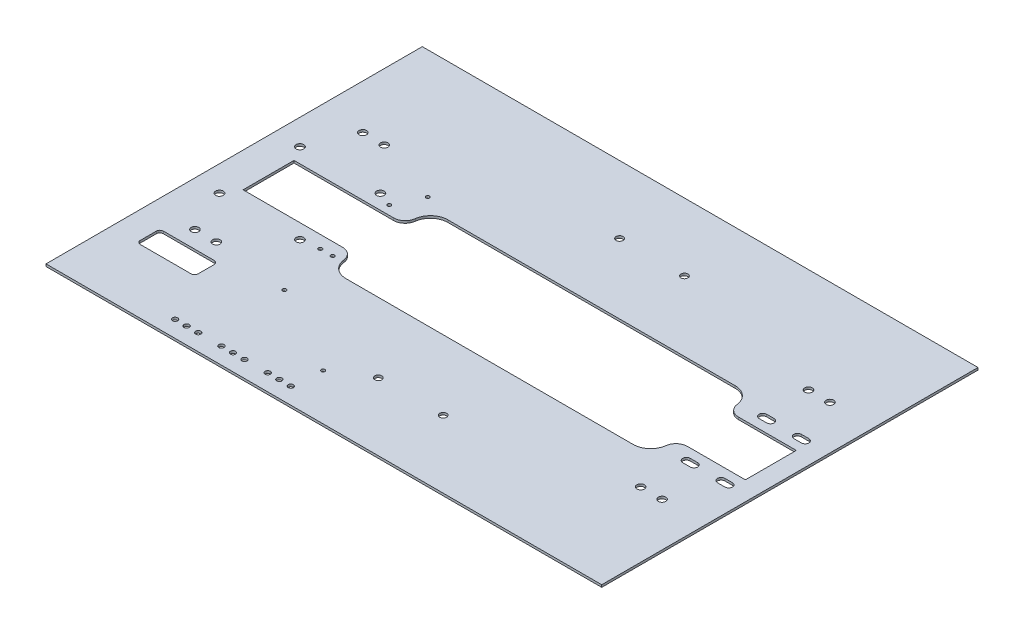
from build123d import *

# Parameters (mm, degrees)
SKETCH1_W           = 480
SKETCH1_H           = 325
BOSS_EXTRUDE1_DEPTH = 2
CUT_EXTRUDE1_REACH  = 4
SKETCH2_R           = 3
CUT_EXTRUDE2_REACH  = 4
FILLET1_R           = 10
CUT_EXTRUDE3_REACH  = 4
SKETCH4_R           = 3.3
FILLET2_R           = 10
CUT_EXTRUDE11_REACH = 4
SKETCH12_R          = 1.5
FILLET3_R           = 15
CUT_EXTRUDE13_DEPTH = 3.0000001
CUT_EXTRUDE14_REACH = 4
SKETCH15_R          = 3.25
CUT_EXTRUDE15_REACH = 4
CUT_EXTRUDE16_REACH = 4
SKETCH17_R          = 1.6
CUT_EXTRUDE17_REACH = 4
SKETCH18_R          = 2.25


with BuildPart() as part:
    # Sketch1 → Boss-Extrude1 (new body)
    with BuildSketch(Plane(origin=(0, 0, 0), x_dir=(1, 0, 0), z_dir=(0, 1, 0))):
        Rectangle(SKETCH1_W, SKETCH1_H)
    extrude(amount=BOSS_EXTRUDE1_DEPTH)

    # Sketch2 → Cut-Extrude1 (cut, up to next)
    with BuildSketch(Plane.XZ, mode=Mode.PRIVATE) as cut_extrude1_sk1:
        with Locations((44.748582867, -104.2)):
            Circle(SKETCH2_R)
    cut_extrude1_tool1 = extrude(cut_extrude1_sk1.sketch, amount=-CUT_EXTRUDE1_REACH, mode=Mode.PRIVATE) & part.part
    add(cut_extrude1_tool1.solids().sort_by_distance((44.748583, 0, -104.2))[0], mode=Mode.SUBTRACT)
    # Sketch2 → Cut-Extrude1 (cut, up to next)
    with BuildSketch(Plane.XZ, mode=Mode.PRIVATE) as cut_extrude1_sk2:
        with Locations((-11.251417133, -104.2)):
            Circle(SKETCH2_R)
    cut_extrude1_tool2 = extrude(cut_extrude1_sk2.sketch, amount=-CUT_EXTRUDE1_REACH, mode=Mode.PRIVATE) & part.part
    add(cut_extrude1_tool2.solids().sort_by_distance((-11.251417, 0, -104.2))[0], mode=Mode.SUBTRACT)
    # Sketch2 → Cut-Extrude1 (cut, up to next)
    with BuildSketch(Plane.XZ, mode=Mode.PRIVATE) as cut_extrude1_sk3:
        with Locations((44.748582867, 104.2)):
            Circle(SKETCH2_R)
    cut_extrude1_tool3 = extrude(cut_extrude1_sk3.sketch, amount=-CUT_EXTRUDE1_REACH, mode=Mode.PRIVATE) & part.part
    add(cut_extrude1_tool3.solids().sort_by_distance((44.748583, 0, 104.2))[0], mode=Mode.SUBTRACT)
    # Sketch2 → Cut-Extrude1 (cut, up to next)
    with BuildSketch(Plane.XZ, mode=Mode.PRIVATE) as cut_extrude1_sk4:
        with Locations((-11.251417133, 104.2)):
            Circle(SKETCH2_R)
    cut_extrude1_tool4 = extrude(cut_extrude1_sk4.sketch, amount=-CUT_EXTRUDE1_REACH, mode=Mode.PRIVATE) & part.part
    add(cut_extrude1_tool4.solids().sort_by_distance((-11.251417, 0, 104.2))[0], mode=Mode.SUBTRACT)

    # Sketch3 → Cut-Extrude2 (cut, up to next)
    with BuildSketch(Plane.XZ, mode=Mode.PRIVATE) as cut_extrude2_sk1:
        Polygon((163.584746975, 44), (-114.288669968, 44), (-114.288669968, 22), (-210.288669968, 22), (-210.288669968, -22), (-114.288669968, -22), (-114.288669968, -44), (163.584746975, -44), (163.584746975, -22), (223.584746975, -22), (223.584746975, 22), (163.584746975, 22), align=None)
    cut_extrude2_tool1 = extrude(cut_extrude2_sk1.sketch, amount=-CUT_EXTRUDE2_REACH, mode=Mode.PRIVATE) & part.part
    add(cut_extrude2_tool1.solids().sort_by_distance((13.675427, 0, 0))[0], mode=Mode.SUBTRACT)

    # Fillet1
    fillet1_edges = [part.edges().sort_by_distance(p)[0] for p in [
        (-114.288669968, 1, -22),
        (-114.288669968, 1, 22),
    ]]
    fillet(fillet1_edges, radius=FILLET1_R)

    # Sketch4 → Cut-Extrude3 (cut, up to next)
    with BuildSketch(Plane.XZ, mode=Mode.PRIVATE) as cut_extrude3_sk1:
        with Locations((-148.425714853, -34.75)):
            Circle(SKETCH4_R)
    cut_extrude3_tool1 = extrude(cut_extrude3_sk1.sketch, amount=-CUT_EXTRUDE3_REACH, mode=Mode.PRIVATE) & part.part
    add(cut_extrude3_tool1.solids().sort_by_distance((-148.425715, 0, -34.75))[0], mode=Mode.SUBTRACT)
    # Sketch4 → Cut-Extrude3 (cut, up to next)
    with BuildSketch(Plane.XZ, mode=Mode.PRIVATE) as cut_extrude3_sk2:
        with Locations((-148.425714853, 34.75)):
            Circle(SKETCH4_R)
    cut_extrude3_tool2 = extrude(cut_extrude3_sk2.sketch, amount=-CUT_EXTRUDE3_REACH, mode=Mode.PRIVATE) & part.part
    add(cut_extrude3_tool2.solids().sort_by_distance((-148.425715, 0, 34.75))[0], mode=Mode.SUBTRACT)
    # Sketch4 → Cut-Extrude3 (cut, up to next)
    with BuildSketch(Plane.XZ, mode=Mode.PRIVATE) as cut_extrude3_sk3:
        with Locations((-217.925714853, 34.75)):
            Circle(SKETCH4_R)
    cut_extrude3_tool3 = extrude(cut_extrude3_sk3.sketch, amount=-CUT_EXTRUDE3_REACH, mode=Mode.PRIVATE) & part.part
    add(cut_extrude3_tool3.solids().sort_by_distance((-217.925715, 0, 34.75))[0], mode=Mode.SUBTRACT)
    # Sketch4 → Cut-Extrude3 (cut, up to next)
    with BuildSketch(Plane.XZ, mode=Mode.PRIVATE) as cut_extrude3_sk4:
        with Locations((-217.925714853, -34.75)):
            Circle(SKETCH4_R)
    cut_extrude3_tool4 = extrude(cut_extrude3_sk4.sketch, amount=-CUT_EXTRUDE3_REACH, mode=Mode.PRIVATE) & part.part
    add(cut_extrude3_tool4.solids().sort_by_distance((-217.925715, 0, -34.75))[0], mode=Mode.SUBTRACT)

    # Fillet2
    fillet2_edges = [part.edges().sort_by_distance(p)[0] for p in [
        (163.584746975, 1, 22),
        (163.584746975, 1, -22),
    ]]
    fillet(fillet2_edges, radius=FILLET2_R)

    # Sketch12 → Cut-Extrude11 (cut, up to next)
    with BuildSketch(Plane.XZ, mode=Mode.PRIVATE) as cut_extrude11_sk1:
        with Locations((-135.781050863, -29.761622515)):
            Circle(SKETCH12_R)
    cut_extrude11_tool1 = extrude(cut_extrude11_sk1.sketch, amount=-CUT_EXTRUDE11_REACH, mode=Mode.PRIVATE) & part.part
    add(cut_extrude11_tool1.solids().sort_by_distance((-135.781051, 0, -29.761623))[0], mode=Mode.SUBTRACT)
    # Sketch12 → Cut-Extrude11 (cut, up to next)
    with BuildSketch(Plane.XZ, mode=Mode.PRIVATE) as cut_extrude11_sk2:
        with Locations((-125.181050863, -52.361622515)):
            Circle(SKETCH12_R)
    cut_extrude11_tool2 = extrude(cut_extrude11_sk2.sketch, amount=-CUT_EXTRUDE11_REACH, mode=Mode.PRIVATE) & part.part
    add(cut_extrude11_tool2.solids().sort_by_distance((-125.181051, 0, -52.361623))[0], mode=Mode.SUBTRACT)

    # Fillet3
    fillet3_edges = [part.edges().sort_by_distance(p)[0] for p in [
        (163.584746975, 1, 44),
        (163.584746975, 1, -44),
        (-114.288669968, 1, 44),
        (-114.288669968, 1, -44),
    ]]
    fillet(fillet3_edges, radius=FILLET3_R)

    # Sketch14 → Cut-Extrude13 (cut, through all)
    with BuildSketch(Plane(origin=(0, 2, 0), x_dir=(1, 0, 0), z_dir=(0, 1, 0))):
        with BuildLine():
            Line((-213.838373062, -87.286543442), (-169.838373062, -87.286543442))
            ThreePointArc((-169.838373062, -87.286543442), (-167.717052718, -88.165223098), (-166.838373062, -90.286543442))
            Line((-166.838373062, -90.286543442), (-166.838373062, -104.286543442))
            ThreePointArc((-166.838373062, -104.286543442), (-167.717052718, -106.407863785), (-169.838373062, -107.286543442))
            Line((-169.838373062, -107.286543442), (-213.838373062, -107.286543442))
            ThreePointArc((-213.838373062, -107.286543442), (-215.959693405, -106.407863785), (-216.838373062, -104.286543442))
            Line((-216.838373062, -104.286543442), (-216.838373062, -90.286543442))
            ThreePointArc((-216.838373062, -90.286543442), (-215.959693405, -88.165223098), (-213.838373062, -87.286543442))
        make_face()
    extrude(amount=-CUT_EXTRUDE13_DEPTH, mode=Mode.SUBTRACT)

    # Sketch15 → Cut-Extrude14 (cut, up to next)
    with BuildSketch(Plane(origin=(0, 2, 0), x_dir=(1, 0, 0), z_dir=(0, 1, 0)), mode=Mode.PRIVATE) as cut_extrude14_sk1:
        with Locations((-201.37519906, -72.5)):
            Circle(SKETCH15_R)
    cut_extrude14_tool1 = extrude(cut_extrude14_sk1.sketch, amount=-CUT_EXTRUDE14_REACH, mode=Mode.PRIVATE) & part.part
    add(cut_extrude14_tool1.solids().sort_by_distance((-201.375199, 2, 72.5))[0], mode=Mode.SUBTRACT)
    # Sketch15 → Cut-Extrude14 (cut, up to next)
    with BuildSketch(Plane(origin=(0, 2, 0), x_dir=(1, 0, 0), z_dir=(0, 1, 0)), mode=Mode.PRIVATE) as cut_extrude14_sk2:
        with Locations((-182.864719491, -72.5)):
            Circle(SKETCH15_R)
    cut_extrude14_tool2 = extrude(cut_extrude14_sk2.sketch, amount=-CUT_EXTRUDE14_REACH, mode=Mode.PRIVATE) & part.part
    add(cut_extrude14_tool2.solids().sort_by_distance((-182.864719, 2, 72.5))[0], mode=Mode.SUBTRACT)
    # Sketch15 → Cut-Extrude14 (cut, up to next)
    with BuildSketch(Plane(origin=(0, 2, 0), x_dir=(1, 0, 0), z_dir=(0, 1, 0)), mode=Mode.PRIVATE) as cut_extrude14_sk3:
        with Locations((-201.37519906, 72.5)):
            Circle(SKETCH15_R)
    cut_extrude14_tool3 = extrude(cut_extrude14_sk3.sketch, amount=-CUT_EXTRUDE14_REACH, mode=Mode.PRIVATE) & part.part
    add(cut_extrude14_tool3.solids().sort_by_distance((-201.375199, 2, -72.5))[0], mode=Mode.SUBTRACT)
    # Sketch15 → Cut-Extrude14 (cut, up to next)
    with BuildSketch(Plane(origin=(0, 2, 0), x_dir=(1, 0, 0), z_dir=(0, 1, 0)), mode=Mode.PRIVATE) as cut_extrude14_sk4:
        with Locations((-182.864719491, 72.5)):
            Circle(SKETCH15_R)
    cut_extrude14_tool4 = extrude(cut_extrude14_sk4.sketch, amount=-CUT_EXTRUDE14_REACH, mode=Mode.PRIVATE) & part.part
    add(cut_extrude14_tool4.solids().sort_by_distance((-182.864719, 2, -72.5))[0], mode=Mode.SUBTRACT)
    # Sketch15 → Cut-Extrude14 (cut, up to next)
    with BuildSketch(Plane(origin=(0, 2, 0), x_dir=(1, 0, 0), z_dir=(0, 1, 0)), mode=Mode.PRIVATE) as cut_extrude14_sk5:
        with Locations((183.62480094, 72.5)):
            Circle(SKETCH15_R)
    cut_extrude14_tool5 = extrude(cut_extrude14_sk5.sketch, amount=-CUT_EXTRUDE14_REACH, mode=Mode.PRIVATE) & part.part
    add(cut_extrude14_tool5.solids().sort_by_distance((183.624801, 2, -72.5))[0], mode=Mode.SUBTRACT)
    # Sketch15 → Cut-Extrude14 (cut, up to next)
    with BuildSketch(Plane(origin=(0, 2, 0), x_dir=(1, 0, 0), z_dir=(0, 1, 0)), mode=Mode.PRIVATE) as cut_extrude14_sk6:
        with Locations((202.135280509, 72.5)):
            Circle(SKETCH15_R)
    cut_extrude14_tool6 = extrude(cut_extrude14_sk6.sketch, amount=-CUT_EXTRUDE14_REACH, mode=Mode.PRIVATE) & part.part
    add(cut_extrude14_tool6.solids().sort_by_distance((202.135281, 2, -72.5))[0], mode=Mode.SUBTRACT)
    # Sketch15 → Cut-Extrude14 (cut, up to next)
    with BuildSketch(Plane(origin=(0, 2, 0), x_dir=(1, 0, 0), z_dir=(0, 1, 0)), mode=Mode.PRIVATE) as cut_extrude14_sk7:
        with Locations((183.62480094, -72.5)):
            Circle(SKETCH15_R)
    cut_extrude14_tool7 = extrude(cut_extrude14_sk7.sketch, amount=-CUT_EXTRUDE14_REACH, mode=Mode.PRIVATE) & part.part
    add(cut_extrude14_tool7.solids().sort_by_distance((183.624801, 2, 72.5))[0], mode=Mode.SUBTRACT)
    # Sketch15 → Cut-Extrude14 (cut, up to next)
    with BuildSketch(Plane(origin=(0, 2, 0), x_dir=(1, 0, 0), z_dir=(0, 1, 0)), mode=Mode.PRIVATE) as cut_extrude14_sk8:
        with Locations((202.135280509, -72.5)):
            Circle(SKETCH15_R)
    cut_extrude14_tool8 = extrude(cut_extrude14_sk8.sketch, amount=-CUT_EXTRUDE14_REACH, mode=Mode.PRIVATE) & part.part
    add(cut_extrude14_tool8.solids().sort_by_distance((202.135281, 2, 72.5))[0], mode=Mode.SUBTRACT)

    # Sketch16 → Cut-Extrude15 (cut, up to next)
    with BuildSketch(Plane(origin=(0, 2, 0), x_dir=(1, 0, 0), z_dir=(0, 1, 0)), mode=Mode.PRIVATE) as cut_extrude15_sk1:
        with BuildLine():
            Line((183.672880587, -36.25), (190.172880587, -36.25))
            ThreePointArc((190.172880587, -36.25), (193.422880587, -33), (190.172880587, -29.75))
            Line((190.172880587, -29.75), (183.672880587, -29.75))
            ThreePointArc((183.672880587, -29.75), (180.422880587, -33), (183.672880587, -36.25))
        make_face()
    cut_extrude15_tool1 = extrude(cut_extrude15_sk1.sketch, amount=-CUT_EXTRUDE15_REACH, mode=Mode.PRIVATE) & part.part
    add(cut_extrude15_tool1.solids().sort_by_distance((186.922881, 2, 33))[0], mode=Mode.SUBTRACT)
    # Sketch16 → Cut-Extrude15 (cut, up to next)
    with BuildSketch(Plane(origin=(0, 2, 0), x_dir=(1, 0, 0), z_dir=(0, 1, 0)), mode=Mode.PRIVATE) as cut_extrude15_sk2:
        with BuildLine():
            Line((213.672880587, -36.25), (220.172880587, -36.25))
            ThreePointArc((220.172880587, -36.25), (223.422880587, -33), (220.172880587, -29.75))
            Line((220.172880587, -29.75), (213.672880587, -29.75))
            ThreePointArc((213.672880587, -29.75), (210.422880587, -33), (213.672880587, -36.25))
        make_face()
    cut_extrude15_tool2 = extrude(cut_extrude15_sk2.sketch, amount=-CUT_EXTRUDE15_REACH, mode=Mode.PRIVATE) & part.part
    add(cut_extrude15_tool2.solids().sort_by_distance((216.922881, 2, 33))[0], mode=Mode.SUBTRACT)
    # Sketch16 → Cut-Extrude15 (cut, up to next)
    with BuildSketch(Plane(origin=(0, 2, 0), x_dir=(1, 0, 0), z_dir=(0, 1, 0)), mode=Mode.PRIVATE) as cut_extrude15_sk3:
        with BuildLine():
            Line((183.672880587, 29.75), (190.172880587, 29.75))
            ThreePointArc((190.172880587, 29.75), (193.422880587, 33), (190.172880587, 36.25))
            Line((190.172880587, 36.25), (183.672880587, 36.25))
            ThreePointArc((183.672880587, 36.25), (180.422880587, 33), (183.672880587, 29.75))
        make_face()
    cut_extrude15_tool3 = extrude(cut_extrude15_sk3.sketch, amount=-CUT_EXTRUDE15_REACH, mode=Mode.PRIVATE) & part.part
    add(cut_extrude15_tool3.solids().sort_by_distance((186.922881, 2, -33))[0], mode=Mode.SUBTRACT)
    # Sketch16 → Cut-Extrude15 (cut, up to next)
    with BuildSketch(Plane(origin=(0, 2, 0), x_dir=(1, 0, 0), z_dir=(0, 1, 0)), mode=Mode.PRIVATE) as cut_extrude15_sk4:
        with BuildLine():
            Line((213.672880587, 29.75), (220.172880587, 29.75))
            ThreePointArc((220.172880587, 29.75), (223.422880587, 33), (220.172880587, 36.25))
            Line((220.172880587, 36.25), (213.672880587, 36.25))
            ThreePointArc((213.672880587, 36.25), (210.422880587, 33), (213.672880587, 29.75))
        make_face()
    cut_extrude15_tool4 = extrude(cut_extrude15_sk4.sketch, amount=-CUT_EXTRUDE15_REACH, mode=Mode.PRIVATE) & part.part
    add(cut_extrude15_tool4.solids().sort_by_distance((216.922881, 2, -33))[0], mode=Mode.SUBTRACT)

    # Sketch17 → Cut-Extrude16 (cut, up to next)
    with BuildSketch(Plane.XZ, mode=Mode.PRIVATE) as cut_extrude16_sk1:
        with Locations((-40.589546706, 122.572891409)):
            Circle(SKETCH17_R)
    cut_extrude16_tool1 = extrude(cut_extrude16_sk1.sketch, amount=-CUT_EXTRUDE16_REACH, mode=Mode.PRIVATE) & part.part
    add(cut_extrude16_tool1.solids().sort_by_distance((-40.589547, 0, 122.572891))[0], mode=Mode.SUBTRACT)
    # Sketch17 → Cut-Extrude16 (cut, up to next)
    with BuildSketch(Plane.XZ, mode=Mode.PRIVATE) as cut_extrude16_sk2:
        with Locations((-117.462873797, 79.100697163)):
            Circle(SKETCH17_R)
    cut_extrude16_tool2 = extrude(cut_extrude16_sk2.sketch, amount=-CUT_EXTRUDE16_REACH, mode=Mode.PRIVATE) & part.part
    add(cut_extrude16_tool2.solids().sort_by_distance((-117.462874, 0, 79.100697))[0], mode=Mode.SUBTRACT)
    # Sketch17 → Cut-Extrude16 (cut, up to next)
    with BuildSketch(Plane.XZ, mode=Mode.PRIVATE) as cut_extrude16_sk3:
        with Locations((-132.735951635, 32.807798569)):
            Circle(SKETCH17_R)
    cut_extrude16_tool3 = extrude(cut_extrude16_sk3.sketch, amount=-CUT_EXTRUDE16_REACH, mode=Mode.PRIVATE) & part.part
    add(cut_extrude16_tool3.solids().sort_by_distance((-132.735952, 0, 32.807799))[0], mode=Mode.SUBTRACT)
    # Sketch17 → Cut-Extrude16 (cut, up to next)
    with BuildSketch(Plane.XZ, mode=Mode.PRIVATE) as cut_extrude16_sk4:
        with Locations((-122.117014245, 32.807798569)):
            Circle(SKETCH17_R)
    cut_extrude16_tool4 = extrude(cut_extrude16_sk4.sketch, amount=-CUT_EXTRUDE16_REACH, mode=Mode.PRIVATE) & part.part
    add(cut_extrude16_tool4.solids().sort_by_distance((-122.117014, 0, 32.807799))[0], mode=Mode.SUBTRACT)

    # Sketch18 → Cut-Extrude17 (cut, up to next)
    with BuildSketch(Plane.XZ, mode=Mode.PRIVATE) as cut_extrude17_sk1:
        with Locations((-42.784434574, 148.220418613)):
            Circle(SKETCH18_R)
    cut_extrude17_tool1 = extrude(cut_extrude17_sk1.sketch, amount=-CUT_EXTRUDE17_REACH, mode=Mode.PRIVATE) & part.part
    add(cut_extrude17_tool1.solids().sort_by_distance((-42.784435, 0, 148.220419))[0], mode=Mode.SUBTRACT)
    # Sketch18 → Cut-Extrude17 (cut, up to next)
    with BuildSketch(Plane.XZ, mode=Mode.PRIVATE) as cut_extrude17_sk2:
        with Locations((-52.784434574, 148.220418613)):
            Circle(SKETCH18_R)
    cut_extrude17_tool2 = extrude(cut_extrude17_sk2.sketch, amount=-CUT_EXTRUDE17_REACH, mode=Mode.PRIVATE) & part.part
    add(cut_extrude17_tool2.solids().sort_by_distance((-52.784435, 0, 148.220419))[0], mode=Mode.SUBTRACT)
    # Sketch18 → Cut-Extrude17 (cut, up to next)
    with BuildSketch(Plane.XZ, mode=Mode.PRIVATE) as cut_extrude17_sk3:
        with Locations((-62.784434574, 148.220418613)):
            Circle(SKETCH18_R)
    cut_extrude17_tool3 = extrude(cut_extrude17_sk3.sketch, amount=-CUT_EXTRUDE17_REACH, mode=Mode.PRIVATE) & part.part
    add(cut_extrude17_tool3.solids().sort_by_distance((-62.784435, 0, 148.220419))[0], mode=Mode.SUBTRACT)
    # Sketch18 → Cut-Extrude17 (cut, up to next)
    with BuildSketch(Plane.XZ, mode=Mode.PRIVATE) as cut_extrude17_sk4:
        with Locations((-82.784434574, 148.220418613)):
            Circle(SKETCH18_R)
    cut_extrude17_tool4 = extrude(cut_extrude17_sk4.sketch, amount=-CUT_EXTRUDE17_REACH, mode=Mode.PRIVATE) & part.part
    add(cut_extrude17_tool4.solids().sort_by_distance((-82.784435, 0, 148.220419))[0], mode=Mode.SUBTRACT)
    # Sketch18 → Cut-Extrude17 (cut, up to next)
    with BuildSketch(Plane.XZ, mode=Mode.PRIVATE) as cut_extrude17_sk5:
        with Locations((-92.784434574, 148.220418613)):
            Circle(SKETCH18_R)
    cut_extrude17_tool5 = extrude(cut_extrude17_sk5.sketch, amount=-CUT_EXTRUDE17_REACH, mode=Mode.PRIVATE) & part.part
    add(cut_extrude17_tool5.solids().sort_by_distance((-92.784435, 0, 148.220419))[0], mode=Mode.SUBTRACT)
    # Sketch18 → Cut-Extrude17 (cut, up to next)
    with BuildSketch(Plane.XZ, mode=Mode.PRIVATE) as cut_extrude17_sk6:
        with Locations((-102.784434574, 148.220418613)):
            Circle(SKETCH18_R)
    cut_extrude17_tool6 = extrude(cut_extrude17_sk6.sketch, amount=-CUT_EXTRUDE17_REACH, mode=Mode.PRIVATE) & part.part
    add(cut_extrude17_tool6.solids().sort_by_distance((-102.784435, 0, 148.220419))[0], mode=Mode.SUBTRACT)
    # Sketch18 → Cut-Extrude17 (cut, up to next)
    with BuildSketch(Plane.XZ, mode=Mode.PRIVATE) as cut_extrude17_sk7:
        with Locations((-122.784434574, 148.220418613)):
            Circle(SKETCH18_R)
    cut_extrude17_tool7 = extrude(cut_extrude17_sk7.sketch, amount=-CUT_EXTRUDE17_REACH, mode=Mode.PRIVATE) & part.part
    add(cut_extrude17_tool7.solids().sort_by_distance((-122.784435, 0, 148.220419))[0], mode=Mode.SUBTRACT)
    # Sketch18 → Cut-Extrude17 (cut, up to next)
    with BuildSketch(Plane.XZ, mode=Mode.PRIVATE) as cut_extrude17_sk8:
        with Locations((-132.784434574, 148.220418613)):
            Circle(SKETCH18_R)
    cut_extrude17_tool8 = extrude(cut_extrude17_sk8.sketch, amount=-CUT_EXTRUDE17_REACH, mode=Mode.PRIVATE) & part.part
    add(cut_extrude17_tool8.solids().sort_by_distance((-132.784435, 0, 148.220419))[0], mode=Mode.SUBTRACT)
    # Sketch18 → Cut-Extrude17 (cut, up to next)
    with BuildSketch(Plane.XZ, mode=Mode.PRIVATE) as cut_extrude17_sk9:
        with Locations((-142.784434574, 148.220418613)):
            Circle(SKETCH18_R)
    cut_extrude17_tool9 = extrude(cut_extrude17_sk9.sketch, amount=-CUT_EXTRUDE17_REACH, mode=Mode.PRIVATE) & part.part
    add(cut_extrude17_tool9.solids().sort_by_distance((-142.784435, 0, 148.220419))[0], mode=Mode.SUBTRACT)


solid = part.part
